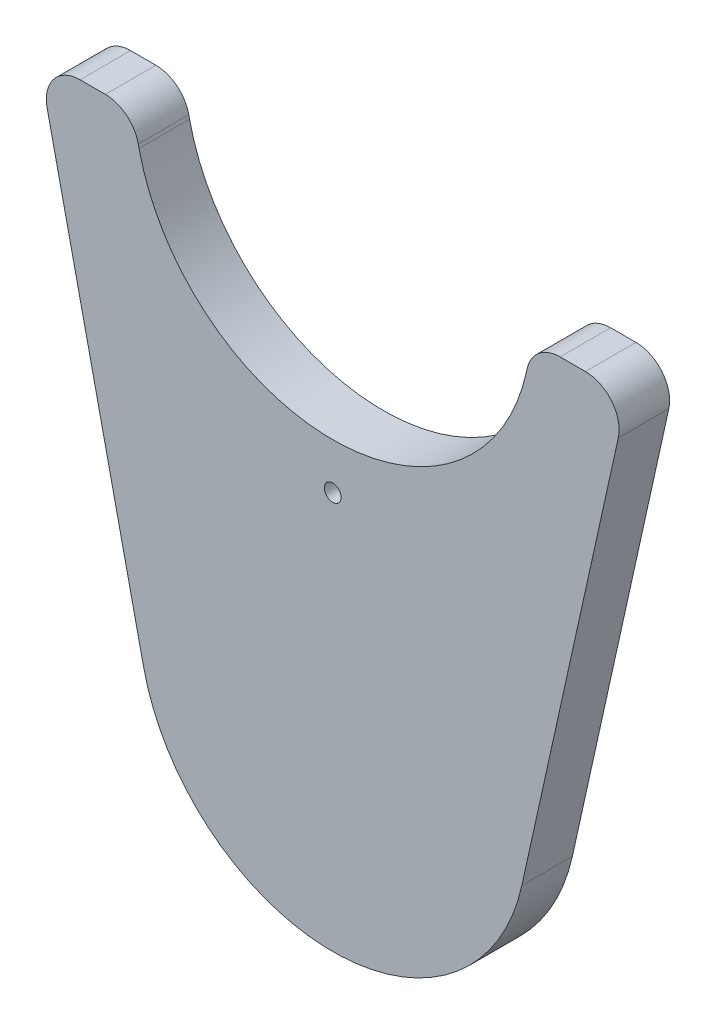
from build123d import *

# Parameters (mm, degrees)
SKETCH1_R           = 2.5
BOSS_EXTRUDE1_DEPTH = 15


with BuildPart() as part:
    # Sketch1 → Boss-Extrude1 (new body)
    with BuildSketch(Plane.XY):
        with BuildLine():
            Line((56.141642872, -12.424408866), (84.779969404, 116.982367581))
            ThreePointArc((84.779969404, 116.982367581), (82.813886735, 125.403818505), (75.016205426, 129.143134341))
            Line((75.016205426, 129.143134341), (67.494400279, 129.143134341))
            ThreePointArc((67.494400279, 129.143134341), (61.233716115, 126.94081565), (57.730636302, 121.3039011))
            Line((57.730636302, 121.3039011), (57.502771105, 120.274256419))
            ThreePointArc((57.502771105, 120.274256419), (0.014621087, 74.105428868), (-57.497228895, 120.244730353))
            Line((-57.497228895, 120.244730353), (-57.731628349, 121.3039011))
            ThreePointArc((-57.731628349, 121.3039011), (-61.234708163, 126.94081565), (-67.495392327, 129.143134341))
            Line((-67.495392327, 129.143134341), (-75.016205426, 129.143134341))
            ThreePointArc((-75.016205426, 129.143134341), (-82.813886735, 125.403818505), (-84.779969404, 116.982367581))
            Line((-84.779969404, 116.982367581), (-56.141642872, -12.424408866))
            ThreePointArc((-56.141642872, -12.424408866), (0, -57.5), (56.141642872, -12.424408866))
        make_face()
        with Locations((0, 60.5)):
            Circle(SKETCH1_R, mode=Mode.SUBTRACT)
    extrude(amount=BOSS_EXTRUDE1_DEPTH)


solid = part.part
